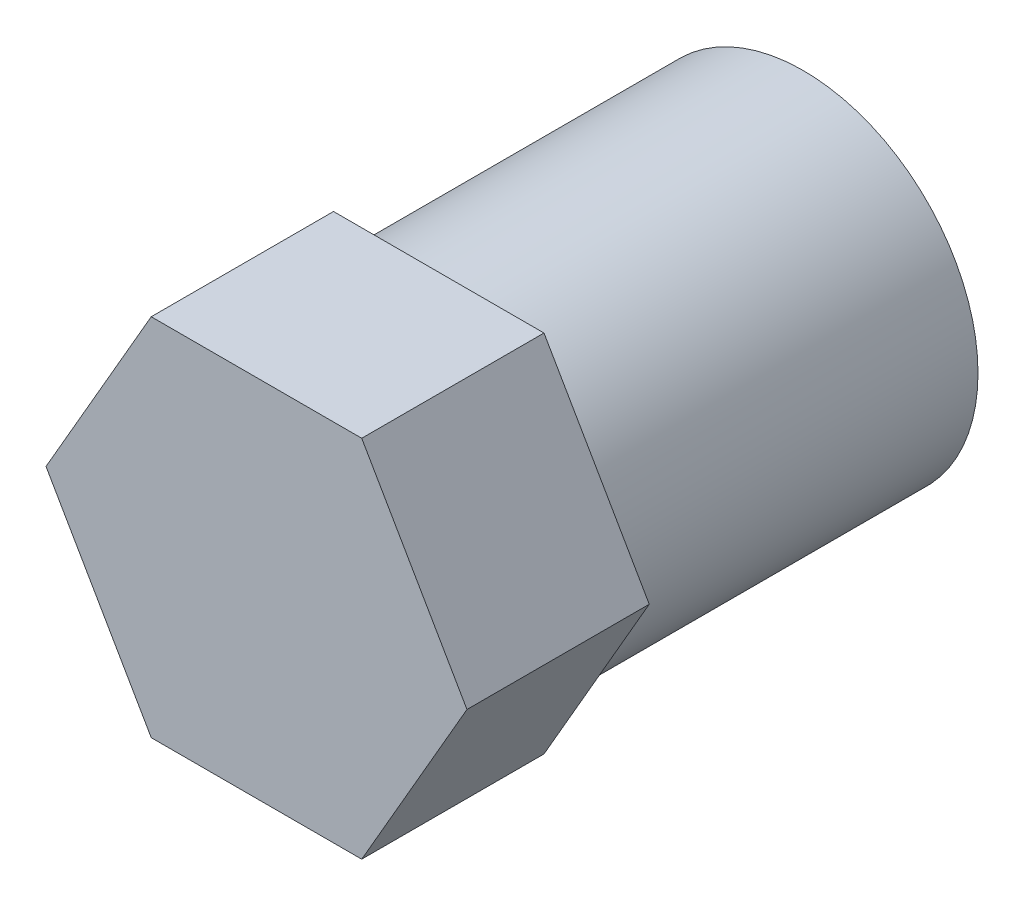
from build123d import *

# Parameters (mm, degrees)
BOSS_EXTRUDE1_DEPTH = 6
SKETCH1_3_R         = 5.75
SKETCH1_3_R_2       = 3
BOSS_EXTRUDE2_DEPTH = 12


with BuildPart() as part:
    # Sketch1 → Boss-Extrude1 (new body)
    with BuildSketch(Plane.XY):
        Polygon((-6.92820323, 0), (-3.464101615, -6), (3.464101615, -6), (6.92820323, 0), (3.464101615, 6), (-3.464101615, 6), align=None)
    extrude(amount=BOSS_EXTRUDE1_DEPTH)

    # Sketch1_3 → Boss-Extrude2 (add)
    with BuildSketch(Plane.XY):
        Circle(SKETCH1_3_R)
        Circle(SKETCH1_3_R_2, mode=Mode.SUBTRACT)
    extrude(amount=-BOSS_EXTRUDE2_DEPTH)


solid = part.part
